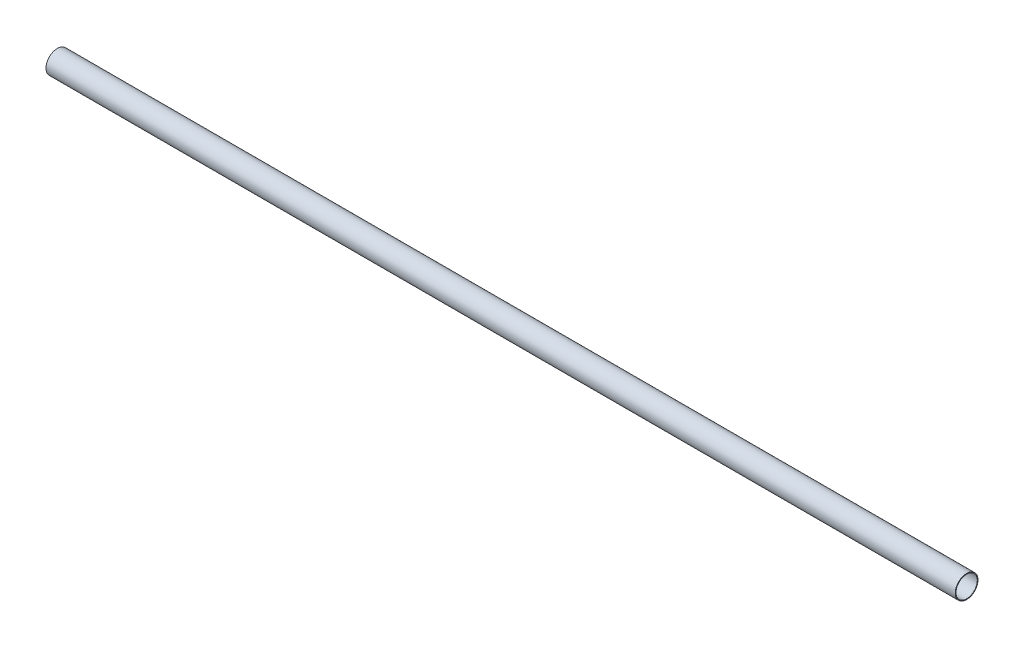
from build123d import *

# Parameters (mm, degrees)
SKETCH_1_R      = 25
SKETCH_1_R_2    = 23.45
EXTRUDE_1_DEPTH = 2000


with BuildPart() as part:
    # Эскиз1 → Бобышка-Вытянуть1 (new body)
    with BuildSketch(Plane(origin=(0, 0, 0), x_dir=(0, 0, -1), z_dir=(1, 0, 0))):
        Circle(SKETCH_1_R)
        Circle(SKETCH_1_R_2, mode=Mode.SUBTRACT)
    extrude(amount=EXTRUDE_1_DEPTH)


solid = part.part
